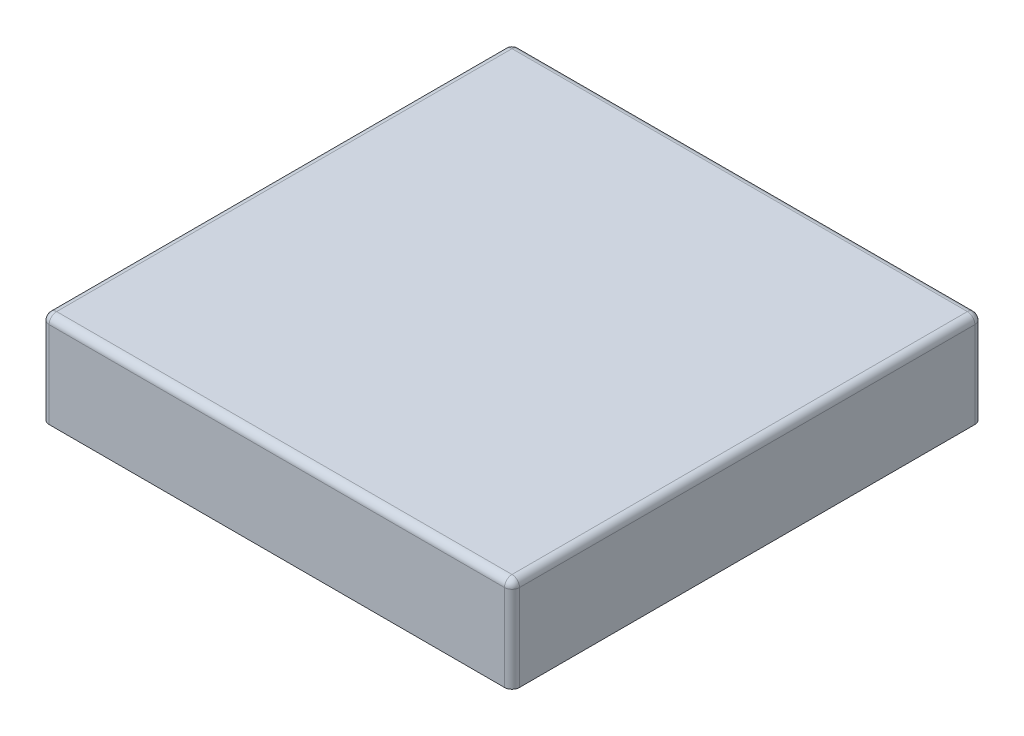
from build123d import *

# Parameters (mm, degrees)
SKETCH2_W           = 15.875
SKETCH2_H           = 15.875
BOSS_EXTRUDE3_DEPTH = 3.175
SHELL1_T            = -1.524
SKETCH5_R           = 3.175
SKETCH5_R_2         = 2.3876
BOSS_EXTRUDE6_DEPTH = 1.651
FILLET1_R           = 0.254


with BuildPart() as part:
    # Sketch2 → Boss-Extrude3 (new body)
    with BuildSketch(Plane(origin=(0, 0, 0), x_dir=(1, 0, 0), z_dir=(0, 1, 0))):
        with Locations((-9.795613381, 0.785891089)):
            Rectangle(SKETCH2_W, SKETCH2_H)
    extrude(amount=BOSS_EXTRUDE3_DEPTH)

    # Shell1
    shell1_openings = [part.faces().sort_by_distance(p)[0] for p in [
        (-9.795613381, 0, -0.785891089),
    ]]
    offset(amount=SHELL1_T, openings=shell1_openings, kind=Kind.INTERSECTION)

    # Sketch5 → Boss-Extrude6 (add)
    with BuildSketch(Plane.XZ):
        with Locations((-9.795613381, -0.785891089)):
            Circle(SKETCH5_R)
        with Locations((-9.795613381, -0.785891089)):
            Circle(SKETCH5_R_2, mode=Mode.SUBTRACT)
    extrude(amount=-BOSS_EXTRUDE6_DEPTH)

    # Fillet1
    fillet1_edges = [part.edges().sort_by_distance(p)[0] for p in [
        (-1.858113381, 3.175, -0.785891089),
        (-9.795613381, 3.175, -8.723391089),
        (-17.733113381, 3.175, -0.785891089),
        (-17.733113381, 1.5875, -8.723391089),
        (-1.858113381, 1.5875, -8.723391089),
        (-1.858113381, 1.5875, 7.151608911),
        (-17.733113381, 1.5875, 7.151608911),
        (-9.795613381, 3.175, 7.151608911),
    ]]
    fillet(fillet1_edges, radius=FILLET1_R)


solid = part.part
